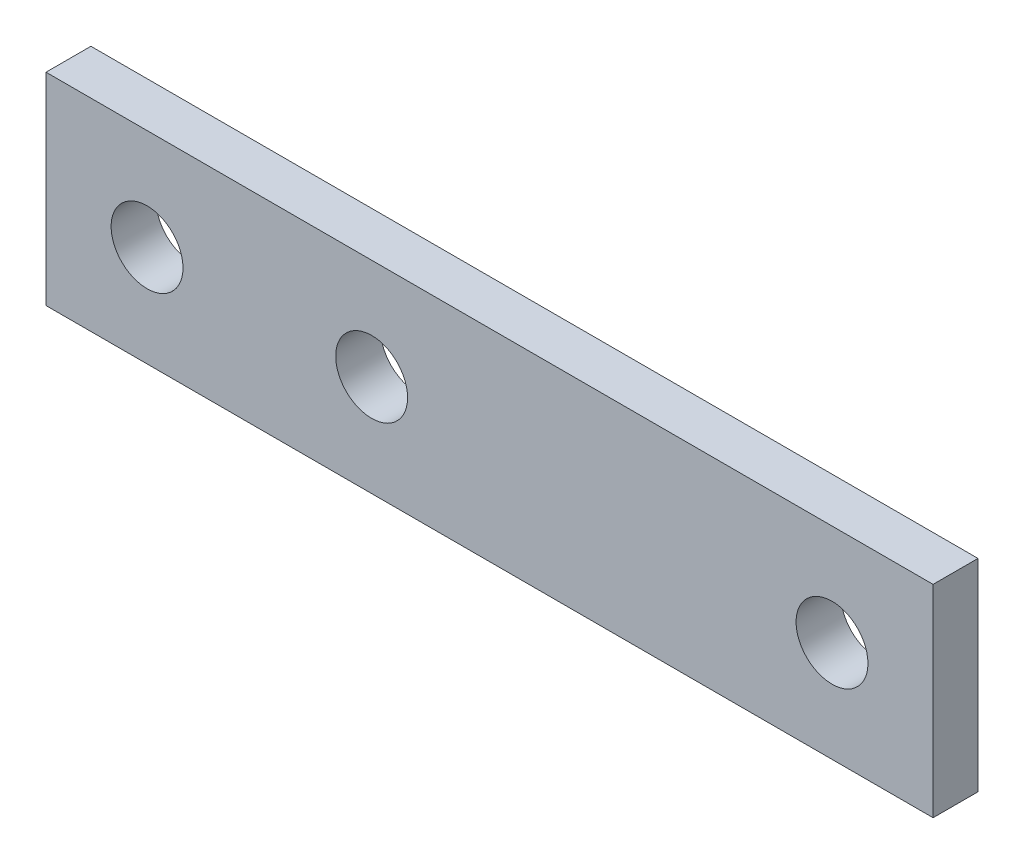
from build123d import *

# Parameters (mm, degrees)
SKETCH_1_W          = 39.5
SKETCH_1_H          = 9
EXTRUDE_1_DEPTH     = 2
SKETCH_2_R          = 1.6
CUT_EXTRUDE_1_DEPTH = 2


with BuildPart() as part:
    # ｽｹｯﾁ1 → ﾎﾞｽ - 押し出し1 (new body)
    with BuildSketch(Plane.XY):
        Rectangle(SKETCH_1_W, SKETCH_1_H)
    extrude(amount=EXTRUDE_1_DEPTH)

    # ｽｹｯﾁ2 → ｶｯﾄ - 押し出し1 (cut)
    with BuildSketch(Plane.XY.offset(2)):
        with Locations((-15.25, 0)):
            Circle(SKETCH_2_R)
        with Locations((-5.25, 0)):
            Circle(SKETCH_2_R)
        with Locations((15.25, 0)):
            Circle(SKETCH_2_R)
    extrude(amount=-CUT_EXTRUDE_1_DEPTH, mode=Mode.SUBTRACT)


solid = part.part
